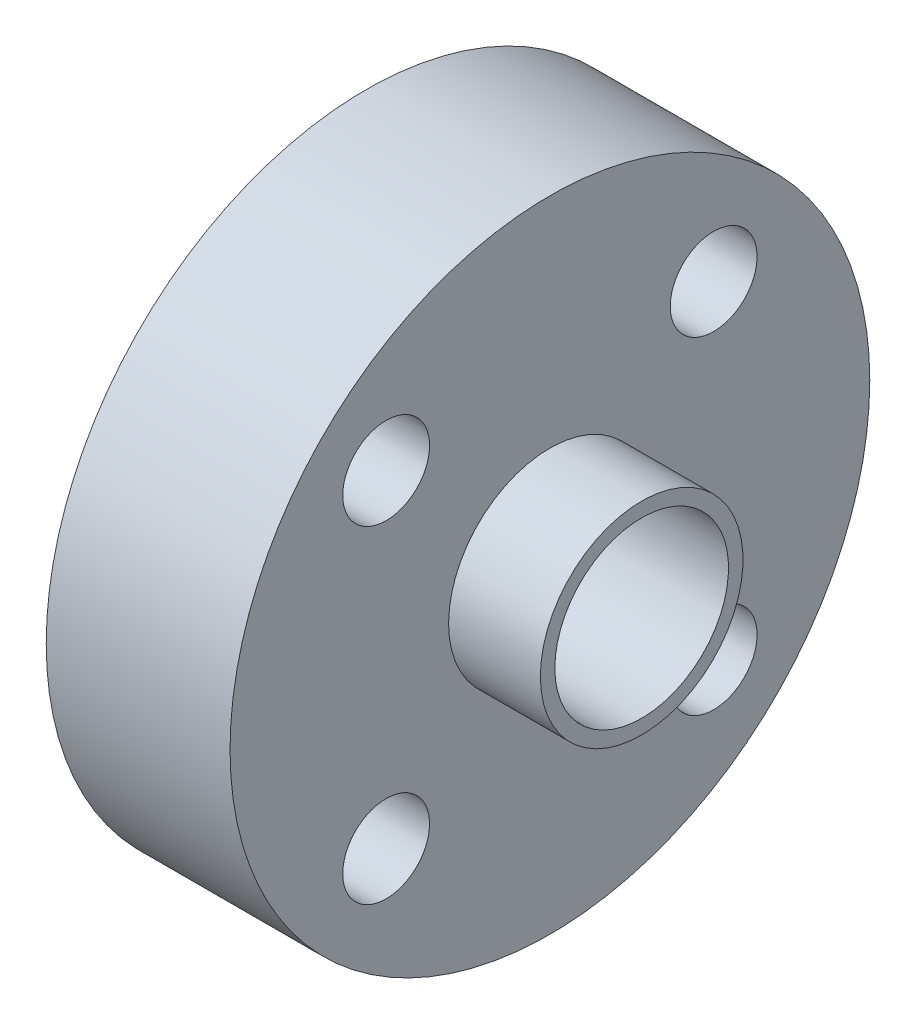
from build123d import *

# Parameters (mm, degrees)
ESQUISSE2_R                  = 3
ENL_V_MAT_EXTRU_1_DEPTH      = 13.7
ESQUISSE3_R                  = 1.5
ENL_V_MAT_EXTRU_2_DEPTH      = 10
R_P_TITION_CIRCULAIRE1_COUNT = 4
ESQUISSE5_R                  = 2.5
ENL_V_MAT_EXTRU_3_DEPTH      = 12.05


with BuildPart() as part:
    # Esquisse1 → Révolution1 (revolve)
    with BuildSketch(Plane(origin=(0, 0, 0), x_dir=(1, 0, 0), z_dir=(0, 1, 0))):
        Polygon((-40.200130208, 0), (-40.200130208, 4.7), (-37.020130208, 4.7), (-37.020130208, 11.05), (-30.670130208, 11.05), (-30.670130208, 3.5), (-27.500130208, 3.5), (-27.500130208, 0), align=None)
    revolve(axis=Axis((-53.297005208, 0, 0), (1, 0, 0)))

    # Esquisse2 → Enlèv. mat.-Extru.1 (cut, through all)
    with BuildSketch(Plane.ZY.offset(40.200130208)):
        Circle(ESQUISSE2_R)
    extrude(amount=-ENL_V_MAT_EXTRU_1_DEPTH, mode=Mode.SUBTRACT)

    # Esquisse3 → Enlèv. mat.-Extru.2 (cut)
    with BuildSketch(Plane.ZY.offset(37.020130208)):
        with Locations((-5.656854249, 5.656854249)):
            Circle(ESQUISSE3_R)
    enl_v_mat_extru_2 = extrude(amount=-ENL_V_MAT_EXTRU_2_DEPTH, mode=Mode.SUBTRACT)

    # Répétition circulaire1: Enlèv. mat.-Extru.2 ×4 about axis
    r_p_tition_circulaire1_axis = Axis((0, 0, 0), (1, 0, 0))
    for i in range(1, R_P_TITION_CIRCULAIRE1_COUNT):
        add(enl_v_mat_extru_2.rotate(r_p_tition_circulaire1_axis, i * 360 / R_P_TITION_CIRCULAIRE1_COUNT), mode=Mode.SUBTRACT)

    # Esquisse5 → Enlèv. mat.-Extru.3 (cut, through all)
    with BuildSketch(Plane.XY):
        with Locations((-33.845130208, 0)):
            Circle(ESQUISSE5_R)
    extrude(amount=-ENL_V_MAT_EXTRU_3_DEPTH, mode=Mode.SUBTRACT)


solid = part.part
